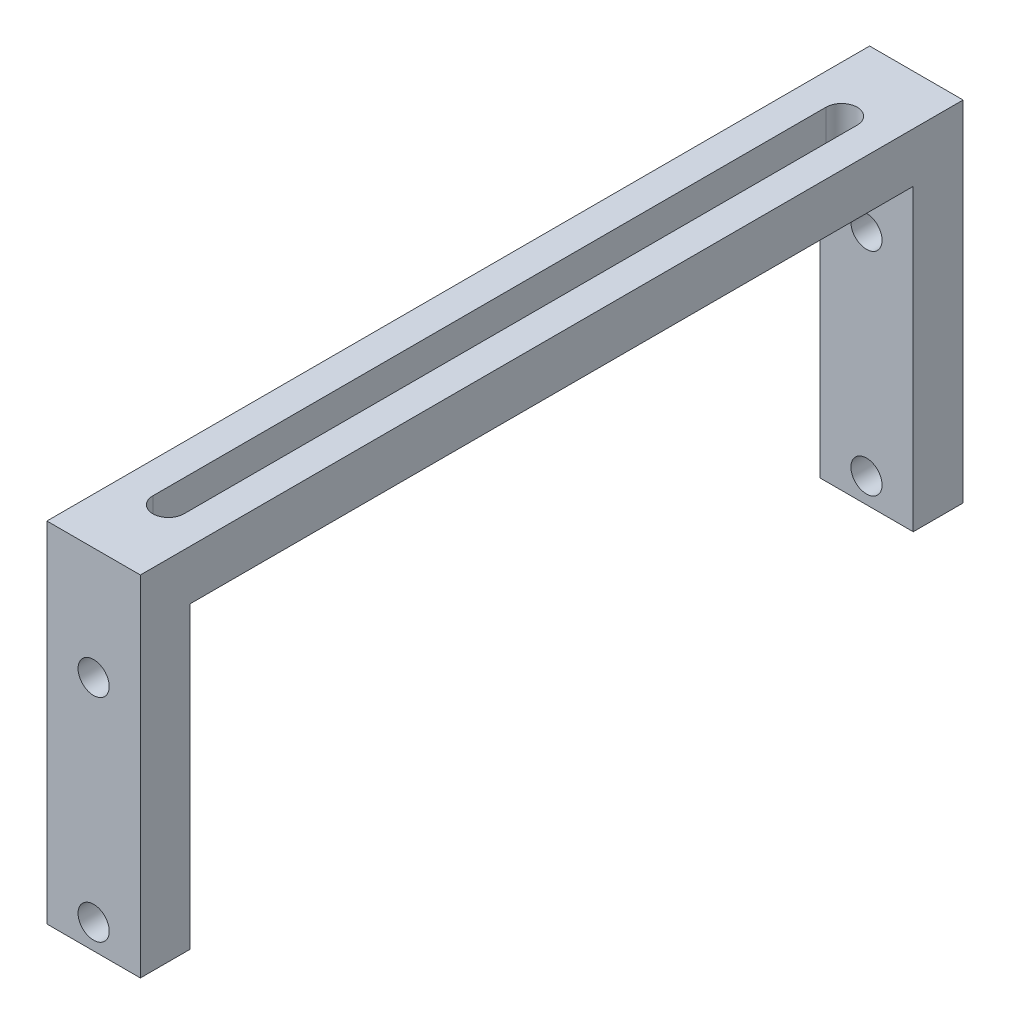
from build123d import *

# Parameters (mm, degrees)
SKETCH1_W           = 9.525
SKETCH1_H           = 35.56
BOSS_EXTRUDE1_DEPTH = 83.82
SKETCH2_W           = 73.66
SKETCH2_H           = 30.48
CUT_EXTRUDE1_DEPTH  = 78.74
CUT_EXTRUDE2_DEPTH  = 78.74
SKETCH4_R           = 1.5875
CUT_EXTRUDE3_DEPTH  = 84.82
SKETCH5_R           = 1.5875
CUT_EXTRUDE4_DEPTH  = 84.82


with BuildPart() as part:
    # Sketch1 → Boss-Extrude1 (new body)
    with BuildSketch(Plane.XY):
        Rectangle(SKETCH1_W, SKETCH1_H)
    extrude(amount=BOSS_EXTRUDE1_DEPTH)

    # Sketch2 → Cut-Extrude1 (cut)
    with BuildSketch(Plane(origin=(4.7625, 0, 0), x_dir=(0, 0, -1), z_dir=(1, 0, 0))):
        with Locations((-41.91, -2.54)):
            Rectangle(SKETCH2_W, SKETCH2_H)
    extrude(amount=-CUT_EXTRUDE1_DEPTH, mode=Mode.SUBTRACT)

    # Sketch3 → Cut-Extrude2 (cut)
    with BuildSketch(Plane(origin=(0, 17.78, 0), x_dir=(1, 0, 0), z_dir=(0, 1, 0))):
        with BuildLine():
            Line((-1.5875, -76.2), (-1.5875, -7.62))
            ThreePointArc((-1.5875, -7.62), (0, -6.0325), (1.5875, -7.62))
            Line((1.5875, -7.62), (1.5875, -76.2))
            ThreePointArc((1.5875, -76.2), (0, -77.7875), (-1.5875, -76.2))
        make_face()
    extrude(amount=-CUT_EXTRUDE2_DEPTH, mode=Mode.SUBTRACT)

    # Sketch4 → Cut-Extrude3 (cut, through all)
    with BuildSketch(Plane.XY.offset(83.82)):
        with Locations((0, -15.24)):
            Circle(SKETCH4_R)
    extrude(amount=-CUT_EXTRUDE3_DEPTH, mode=Mode.SUBTRACT)

    # Sketch5 → Cut-Extrude4 (cut, through all)
    with BuildSketch(Plane.XY.offset(83.82)):
        with Locations((0, 6.35)):
            Circle(SKETCH5_R)
    extrude(amount=-CUT_EXTRUDE4_DEPTH, mode=Mode.SUBTRACT)


solid = part.part
